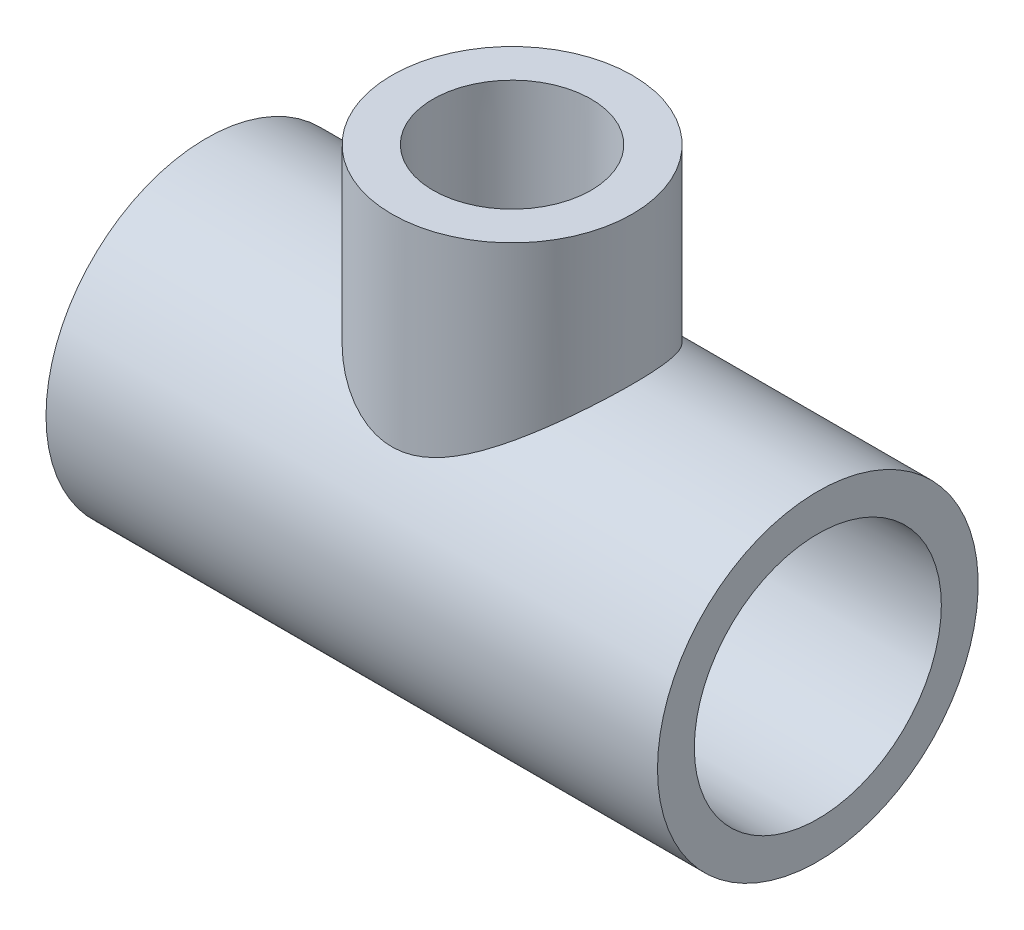
from build123d import *

# Parameters (mm, degrees)
SKETCH4_R           = 21.844
BOSS_EXTRUDE1_DEPTH = 25.4
SKETCH5_R           = 16.383
BOSS_EXTRUDE2_DEPTH = 19.05


with BuildPart() as part:
    # Sketch1 → Revolve1 (revolve)
    with BuildSketch(Plane.XY, mode=Mode.PRIVATE) as revolve1_sk:
        Polygon((-41.656, -21.844), (-12.7, -21.844), (-12.7, -16.637), (-41.656, -16.8275), align=None)
        Polygon((41.656, -16.8275), (12.7, -16.637), (12.7, -21.844), (41.656, -21.844), align=None)
    revolve(revolve1_sk.sketch.rotate(Axis((-41.656, 0, 0), (1, 0, 0)), 270), axis=Axis((-41.656, 0, 0), (1, 0, 0)))



with BuildPart() as body_2:
    # Sketch2 → Revolve2 (revolve)
    with BuildSketch(Plane.XY):
        Polygon((10.7696, 41.91), (10.6172, 19.05), (16.383, 19.05), (16.383, 41.91), align=None)
    revolve(axis=Axis((0, 0, 0), (0, 1, 0)))


with BuildPart() as part_1:
    add(part.part)

    add(body_2.part)  # Boss-Extrude1 merges body 2
    # Sketch4 → Boss-Extrude1 (add)
    with BuildSketch(Plane(origin=(-12.7, 0, 0), x_dir=(0, 0, -1), z_dir=(1, 0, 0))):
        with Locations(Location((0, 0, 0), (0, 0, 180))):
            Circle(SKETCH4_R)
    extrude(amount=BOSS_EXTRUDE1_DEPTH)

    # Sketch5 → Boss-Extrude2 (add)
    with BuildSketch(Plane.XZ.offset(-19.05)):
        Circle(SKETCH5_R)
    extrude(amount=BOSS_EXTRUDE2_DEPTH)

    # Sketch6 → Cut-Revolve1 (revolve, cut)
    with BuildSketch(Plane.XY, mode=Mode.PRIVATE) as cut_revolve1_sk:
        Polygon((-41.656, -16.8275), (-12.7, -16.637), (-12.7, -12.1539), (12.7, -12.1539), (12.7, -16.637), (41.656, -16.8275), (41.656, 0), (-41.656, 0), align=None)
    revolve(cut_revolve1_sk.sketch.rotate(Axis((41.656, 0, 0), (-1, 0, 0)), 270), axis=Axis((41.656, 0, 0), (-1, 0, 0)), mode=Mode.SUBTRACT)

    # Sketch7 → Cut-Revolve2 (revolve, cut)
    with BuildSketch(Plane.XY):
        Polygon((10.7696, 41.91), (10.6172, 19.05), (6.9342, 19.05), (6.9342, 0), (0, 0), (0, 41.91), align=None)
    revolve(axis=Axis((0, 0, 0), (0, 1, 0)), mode=Mode.SUBTRACT)


solid = part_1.part
